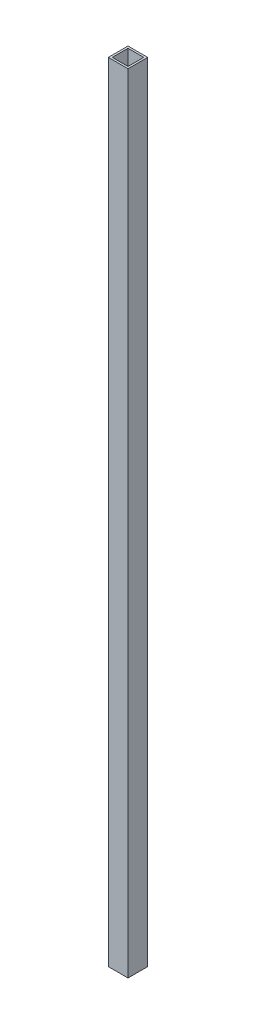
from build123d import *

# Parameters (mm, degrees)
SKETCH1_W           = 20
SKETCH1_H           = 800
BOSS_EXTRUDE1_DEPTH = 20
SKETCH2_W           = 16
SKETCH2_H           = 16
CUT_EXTRUDE1_DEPTH  = 200


with BuildPart() as part:
    # Sketch1 → Boss-Extrude1 (new body)
    with BuildSketch(Plane.XY):
        with Locations((-21.739130435, -350.217391304)):
            Rectangle(SKETCH1_W, SKETCH1_H)
    extrude(amount=-BOSS_EXTRUDE1_DEPTH)

    # Sketch2 → Cut-Extrude1 (cut)
    with BuildSketch(Plane(origin=(0, 49.782608696, 0), x_dir=(1, 0, 0), z_dir=(0, 1, 0))):
        with Locations((-21.739130435, 10)):
            Rectangle(SKETCH2_W, SKETCH2_H)
    extrude(amount=-CUT_EXTRUDE1_DEPTH, mode=Mode.SUBTRACT)


solid = part.part
